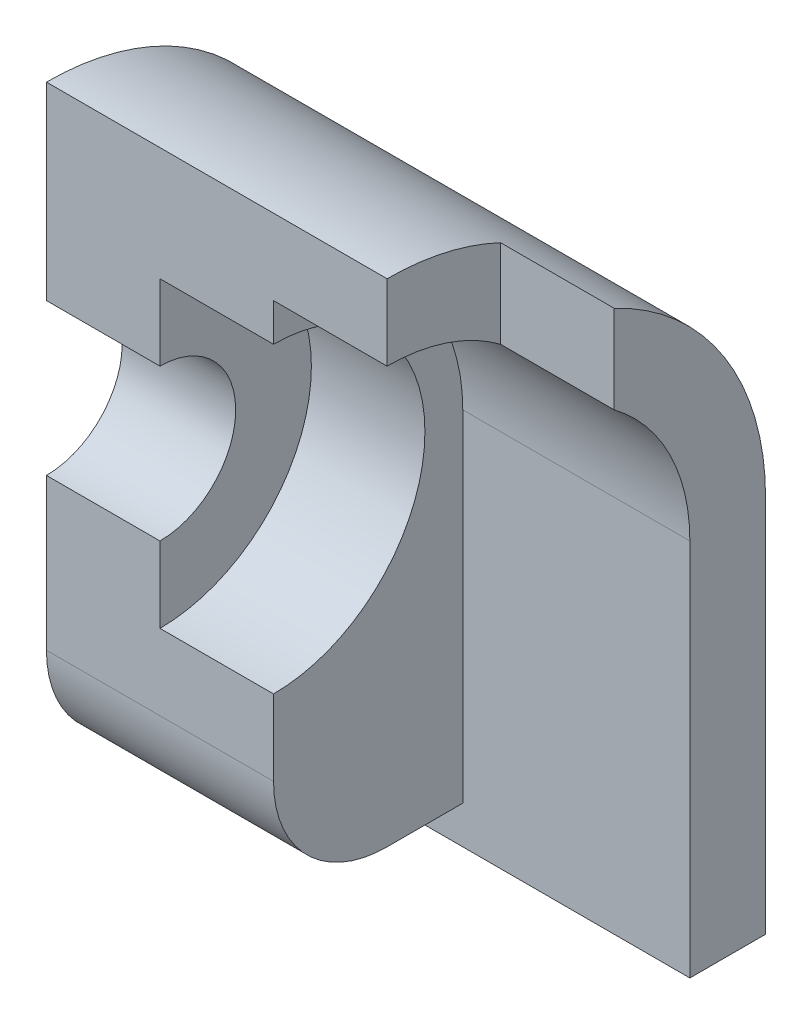
from build123d import *

# Parameters (mm, degrees)
SKETCH1_W           = 2
SKETCH1_H           = 1
BOSS_EXTRUDE1_DEPTH = 12
SKETCH2_W           = 3
SKETCH2_H           = 3
CUT_EXTRUDE1_DEPTH  = 22
CUT_EXTRUDE2_DEPTH  = 6
SKETCH4_R           = 4
CUT_EXTRUDE3_DEPTH  = 3


with BuildPart() as part:
    # Sketch1 → Boss-Extrude1 (new body)
    with BuildSketch(Plane(origin=(0, 0, 0), x_dir=(0, 0, -1), z_dir=(1, 0, 0))):
        with BuildLine():
            Line((1.5, -8), (3.5, -8))
            Line((3.5, -8), (3.5, 1))
            ThreePointArc((3.5, 1), (1.449747468, 5.949747468), (-3.5, 8))
            Line((-3.5, 8), (-3.5, 3))
            ThreePointArc((-3.5, 3), (-2.085786438, 2.414213562), (-1.5, 1))
            ThreePointArc((-1.5, 1), (-2.085786438, -0.414213562), (-3.5, -1))
            Line((-3.5, -1), (-3.5, -5))
            ThreePointArc((-3.5, -5), (-2.621320344, -7.121320344), (-0.5, -8))
            Line((-0.5, -8), (1.5, -8))
        make_face()
        with Locations((2.5, -8.5)):
            Rectangle(SKETCH1_W, SKETCH1_H)
    extrude(amount=BOSS_EXTRUDE1_DEPTH)

    # Sketch2 → Cut-Extrude1 (cut)
    with BuildSketch(Plane.XZ.offset(9)):
        with Locations((10.5, 2)):
            Rectangle(SKETCH2_W, SKETCH2_H)
    extrude(amount=-CUT_EXTRUDE1_DEPTH, mode=Mode.SUBTRACT)

    # Sketch3 → Cut-Extrude2 (cut)
    with BuildSketch(Plane(origin=(12, 0, 0), x_dir=(0, 0, -1), z_dir=(1, 0, 0))):
        with BuildLine():
            Line((1.5, 1), (1.5, -8.778964662))
            ThreePointArc((1.5, -8.778964662), (-3.5, -13.778964662), (-8.5, -8.778964662))
            Line((-8.5, -8.778964662), (-8.5, 1))
            ThreePointArc((-8.5, 1), (-3.5, 6), (1.5, 1))
        make_face()
    extrude(amount=-CUT_EXTRUDE2_DEPTH, mode=Mode.SUBTRACT)

    # Sketch4 → Cut-Extrude3 (cut)
    with BuildSketch(Plane(origin=(6, 0, 0), x_dir=(0, 0, -1), z_dir=(1, 0, 0))):
        with Locations((-3.5, 1)):
            Circle(SKETCH4_R)
    extrude(amount=-CUT_EXTRUDE3_DEPTH, mode=Mode.SUBTRACT)


solid = part.part
